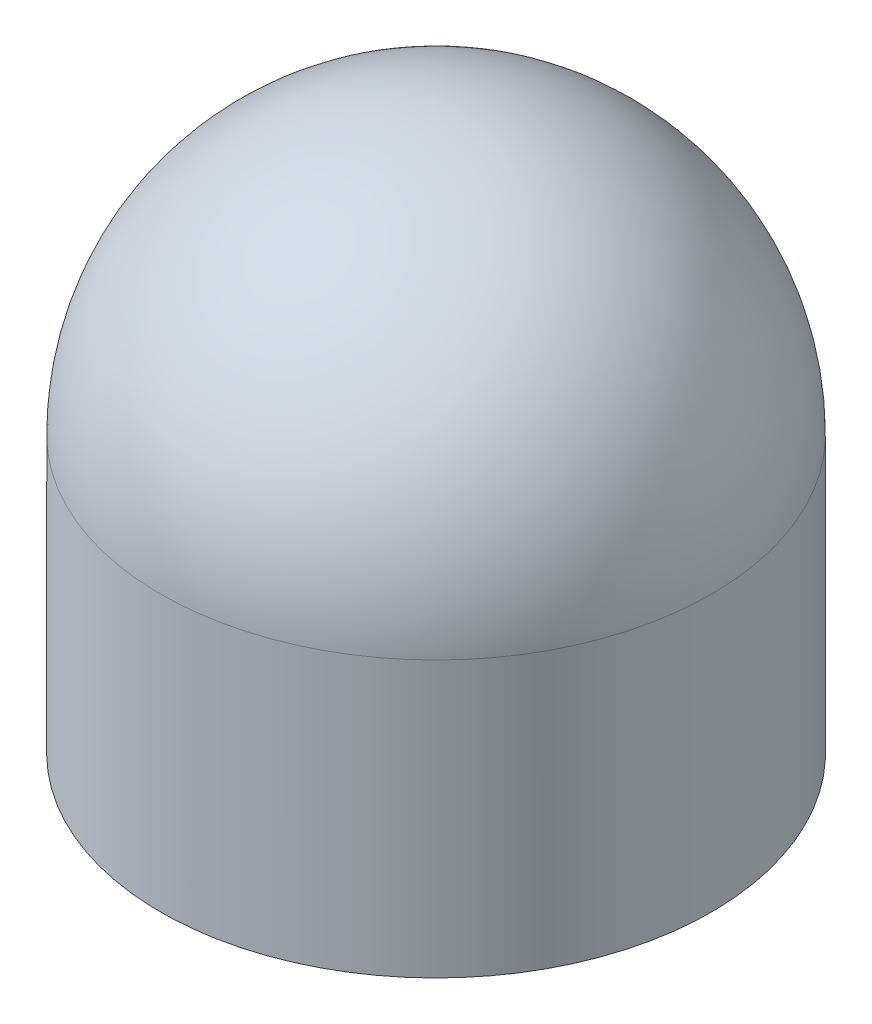
from build123d import *


with BuildPart() as part:
    # Sketch1 → Revolve1 (revolve)
    with BuildSketch(Plane.XY, mode=Mode.PRIVATE) as revolve1_sk:
        with BuildLine():
            Line((0, 0), (0, 12.7))
            ThreePointArc((0, 12.7), (-4.490128061, 10.840128061), (-6.35, 6.35))
            Line((-6.35, 6.35), (-6.35, 0))
            Line((-6.35, 0), (0, 0))
        make_face()
    revolve(revolve1_sk.sketch.rotate(Axis((0, 0, 0), (0, 1, 0)), 270), axis=Axis((0, 0, 0), (0, 1, 0)))  # turned: the seam where the file's is


solid = part.part
